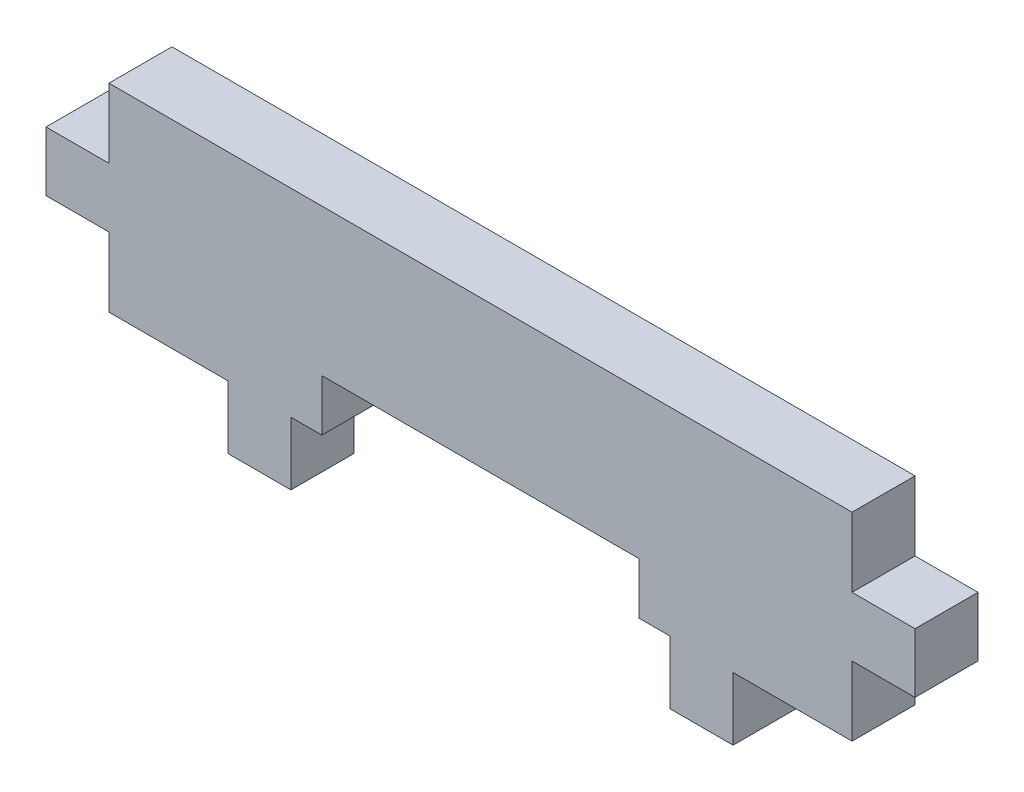
from build123d import *

# Parameters (mm, degrees)
BOSS_EXTRUDE1_DEPTH = 3.175


with BuildPart() as part:
    # Sketch2 → Boss-Extrude1 (new body)
    with BuildSketch(Plane.XY):
        Polygon((12.735, -11.177615915), (12.735, -14.352615915), (9.56, -14.352615915), (9.56, -11.177615915), (8, -11.177615915), (8, -8.577615915), (-8, -8.577615915), (-8, -11.177615915), (-9.56, -11.177615915), (-9.56, -14.352615915), (-12.735, -14.352615915), (-12.735, -11.177615915), (-18.735, -11.177615915), (-18.735, -7.677615915), (-21.91, -7.677615915), (-21.91, -4.677615915), (-18.735, -4.677615915), (-18.735, -1.177615915), (18.735, -1.177615915), (18.735, -4.677615915), (21.91, -4.677615915), (21.91, -7.677615915), (18.735, -7.677615915), (18.735, -11.177615915), align=None)
    extrude(amount=-BOSS_EXTRUDE1_DEPTH)


solid = part.part
